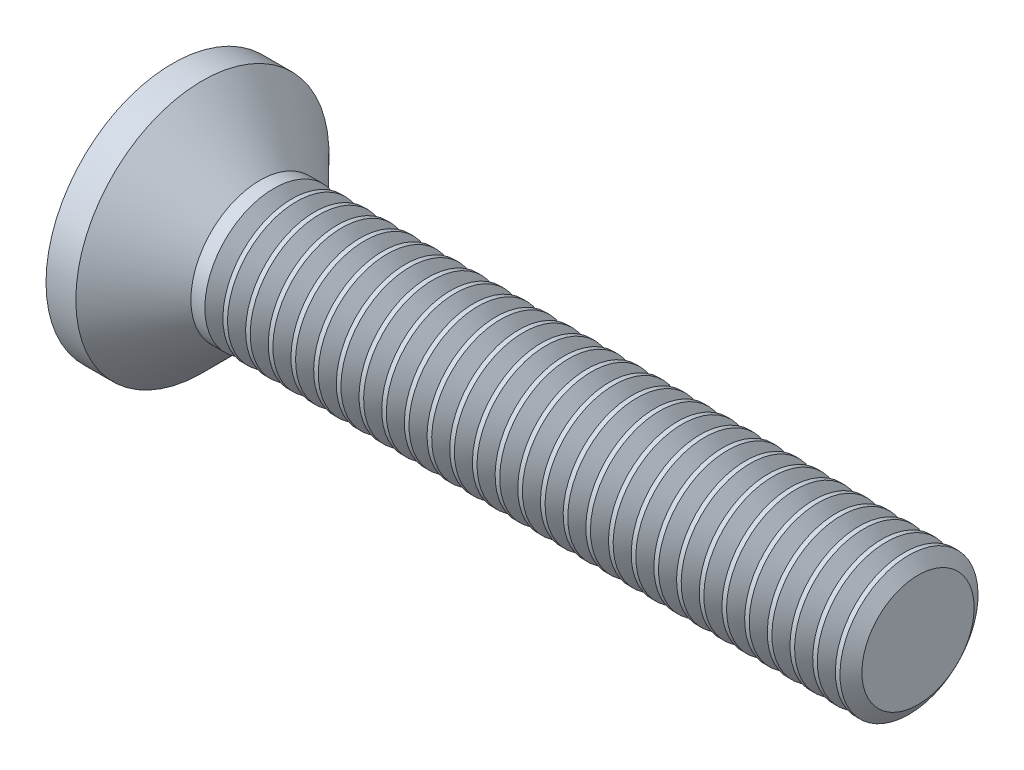
from build123d import *

# Parameters (mm, degrees)
SKETCH3_W         = 0.83
SKETCH3_H         = 3.44
SKETCH4_W         = 0.415
SKETCH4_H         = 0.415
CIRPATTERN1_COUNT = 2
CIRPATTERN1_ANGLE = 90
THDSCHPAT_COUNT   = 29
THDSCHPAT_PITCH   = 0.492857143


with BuildPart() as part:
    # BodySke → Base-Revolve (revolve)
    with BuildSketch(Plane.XY, mode=Mode.PRIVATE) as base_revolve_sk:
        with BuildLine():
            Line((0, 0), (16.727669073, 0))
            Line((16.727669073, 0), (16.727669073, 1.5))
            Line((16.727669073, 1.5), (2.427669073, 1.5))
            Line((2.427669073, 1.5), (1.177669073, 2.75))
            Line((1.177669073, 2.75), (0.529956332, 2.75))
            ThreePointArc((0.529956332, 2.75), (0.133696843, 1.400299407), (0, 0))
        make_face()
    revolve(base_revolve_sk.sketch.rotate(Axis((-15.875, 0, 0), (1, 0, 0)), 90), axis=Axis((-15.875, 0, 0), (1, 0, 0)))

    # Sketch3 → Cross section 0
    with BuildSketch(Plane(origin=(0, 0, 0), x_dir=(0, 0, -1), z_dir=(1, 0, 0))):
        Rectangle(SKETCH3_W, SKETCH3_H)
    # Sketch4 → Cross section 1
    with BuildSketch(Plane(origin=(2.33, 0, 0), x_dir=(0, 0, -1), z_dir=(1, 0, 0))):
        Rectangle(SKETCH4_W, SKETCH4_H)
    cross = loft(mode=Mode.SUBTRACT)

    # CirPattern1: Cross ×2 about axis
    cirpattern1_axis = Axis((0, 0, 0), (1, 0, 0))
    for i in range(1, CIRPATTERN1_COUNT):
        add(cross.rotate(cirpattern1_axis, i * CIRPATTERN1_ANGLE / (CIRPATTERN1_COUNT - 1)), mode=Mode.SUBTRACT)

    # ThdSchSke → ThreadSchematic (revolve, cut)
    with BuildSketch(Plane.XY):
        Polygon((2.927669073, -1.2195), (2.731260858, -1.5), (2.731260858, -1.875), (3.124077287, -1.875), (3.124077287, -1.5), align=None)
    threadschematic = revolve(axis=Axis((-3.175, 0, 0), (1, 0, 0)), mode=Mode.SUBTRACT)

    # ThdSchPat: ThreadSchematic ×29
    with Locations(*[(i * THDSCHPAT_PITCH, 0, 0) for i in range(1, THDSCHPAT_COUNT)]):
        add(threadschematic, mode=Mode.SUBTRACT)


solid = part.part
